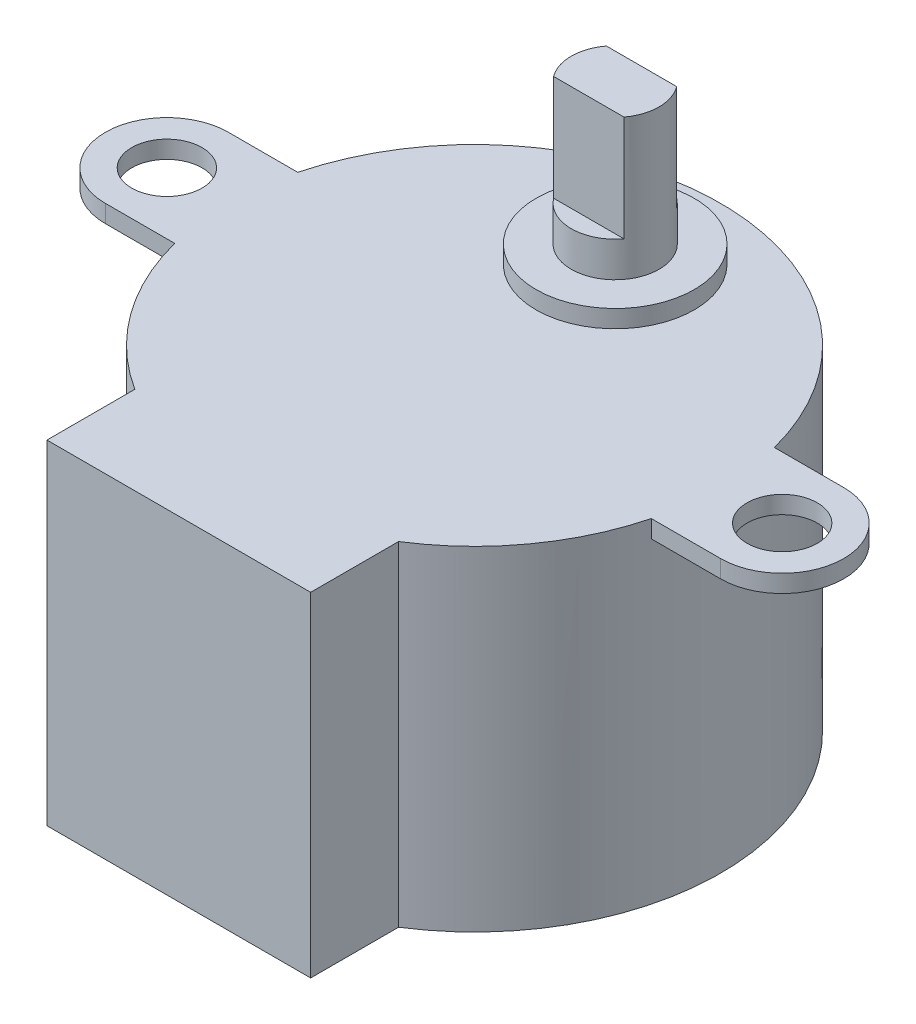
from build123d import *

# Parameters (mm, degrees)
BOSS_EXTRU_1_DEPTH      = 19
ESQUISSE2_R             = 2
BOSS_EXTRU_2_DEPTH      = 1
ESQUISSE3_R             = 4.5
BOSS_EXTRU_3_DEPTH      = 1
ESQUISSE4_R             = 2.5
BOSS_EXTRU_4_DEPTH      = 8
ENL_V_MAT_EXTRU_1_DEPTH = 6


with BuildPart() as part:
    # Esquisse1 → Boss.-Extru.1 (new body)
    with BuildSketch(Plane(origin=(0, 0, 0), x_dir=(1, 0, 0), z_dir=(0, 1, 0))):
        with BuildLine():
            Line((-7.5, -11.821590418), (-7.5, -16.821590418))
            Line((-7.5, -16.821590418), (7.5, -16.821590418))
            Line((7.5, -16.821590418), (7.5, -11.821590418))
            ThreePointArc((7.5, -11.821590418), (0, 14), (-7.5, -11.821590418))
        make_face()
    extrude(amount=BOSS_EXTRU_1_DEPTH)

    # Esquisse2 → Boss.-Extru.2 (add)
    with BuildSketch(Plane(origin=(0, 19, 0), x_dir=(1, 0, 0), z_dir=(0, 1, 0))):
        with BuildLine():
            Line((13.555441712, 3.5), (17.5, 3.5))
            ThreePointArc((17.5, 3.5), (21, 0), (17.5, -3.5))
            Line((17.5, -3.5), (13.555441712, -3.5))
            ThreePointArc((13.555441712, -3.5), (14, 0), (13.555441712, 3.5))
        make_face()
        with Locations((17.5, 0)):
            Circle(ESQUISSE2_R, mode=Mode.SUBTRACT)
        with BuildLine():
            Line((-17.5, -3.5), (-13.555441712, -3.5))
            ThreePointArc((-13.555441712, -3.5), (-14, 0), (-13.555441712, 3.5))
            Line((-13.555441712, 3.5), (-17.5, 3.5))
            ThreePointArc((-17.5, 3.5), (-21, 0), (-17.5, -3.5))
        make_face()
        with Locations((-17.5, 0)):
            Circle(ESQUISSE2_R, mode=Mode.SUBTRACT)
    extrude(amount=-BOSS_EXTRU_2_DEPTH)

    # Esquisse3 → Boss.-Extru.3 (add)
    with BuildSketch(Plane(origin=(0, 19, 0), x_dir=(1, 0, 0), z_dir=(0, 1, 0))):
        with Locations((0, 8)):
            Circle(ESQUISSE3_R)
    extrude(amount=BOSS_EXTRU_3_DEPTH)

    # Esquisse4 → Boss.-Extru.4 (add)
    with BuildSketch(Plane(origin=(0, 20, 0), x_dir=(1, 0, 0), z_dir=(0, 1, 0))):
        with Locations((0, 8)):
            Circle(ESQUISSE4_R)
    extrude(amount=BOSS_EXTRU_4_DEPTH)

    # Esquisse5 → Enlèv. mat.-Extru.1 (cut)
    with BuildSketch(Plane(origin=(0, 28, 0), x_dir=(1, 0, 0), z_dir=(0, 1, 0))):
        with BuildLine():
            Line((2, 6.5), (-2, 6.5))
            ThreePointArc((-2, 6.5), (0, 5.5), (2, 6.5))
        make_face()
        with BuildLine():
            ThreePointArc((2, 9.5), (0, 10.5), (-2, 9.5))
            Line((-2, 9.5), (2, 9.5))
        make_face()
    extrude(amount=-ENL_V_MAT_EXTRU_1_DEPTH, mode=Mode.SUBTRACT)


solid = part.part
